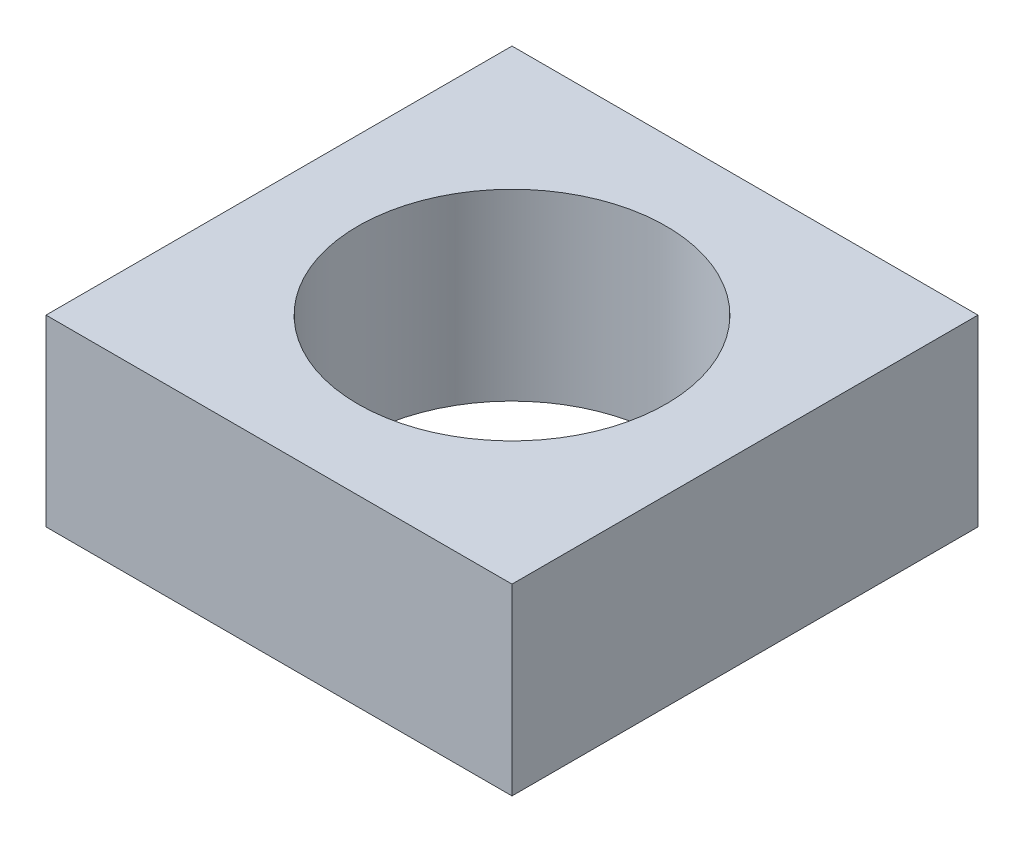
from build123d import *

# Parameters (mm, degrees)
SKETCH1_W           = 12.7
SKETCH1_H           = 12.7
SKETCH1_R           = 4.2
BOSS_EXTRUDE1_DEPTH = 5


with BuildPart() as part:
    # Sketch1 → Boss-Extrude1 (new body)
    with BuildSketch(Plane(origin=(0, 0, 0), x_dir=(1, 0, 0), z_dir=(0, 1, 0))):
        Rectangle(SKETCH1_W, SKETCH1_H)
        Circle(SKETCH1_R, mode=Mode.SUBTRACT)
    extrude(amount=BOSS_EXTRUDE1_DEPTH)


solid = part.part
